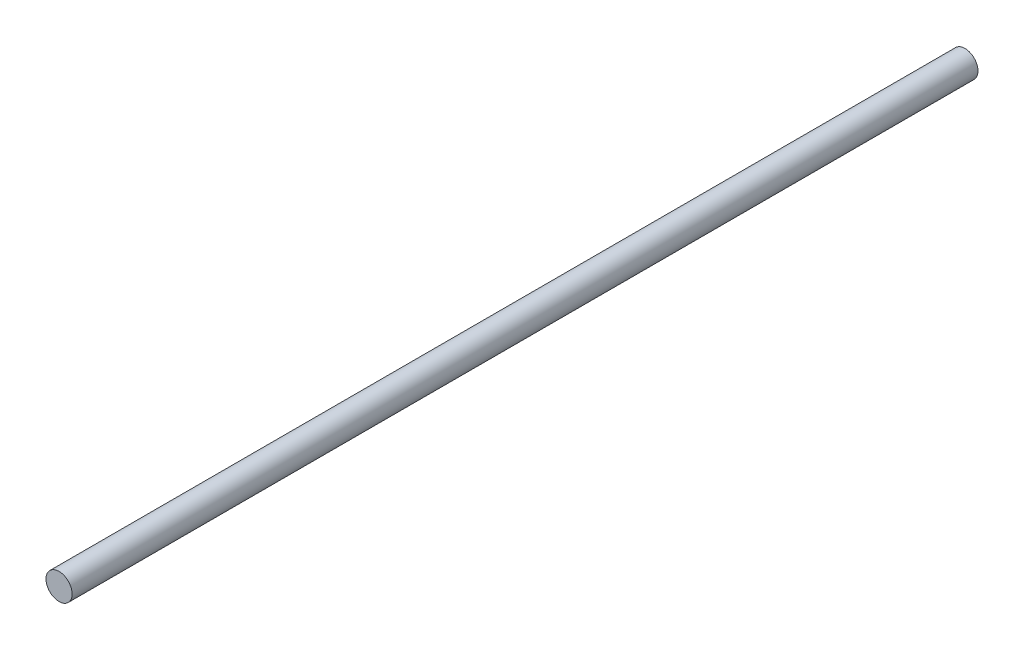
from build123d import *

# Parameters (mm, degrees)
SKETCH1_R           = 1.5
BOSS_EXTRUDE1_DEPTH = 104


with BuildPart() as part:
    # Sketch1 → Boss-Extrude1 (new body)
    with BuildSketch(Plane.XY):
        Circle(SKETCH1_R)
    extrude(amount=BOSS_EXTRUDE1_DEPTH)


solid = part.part
